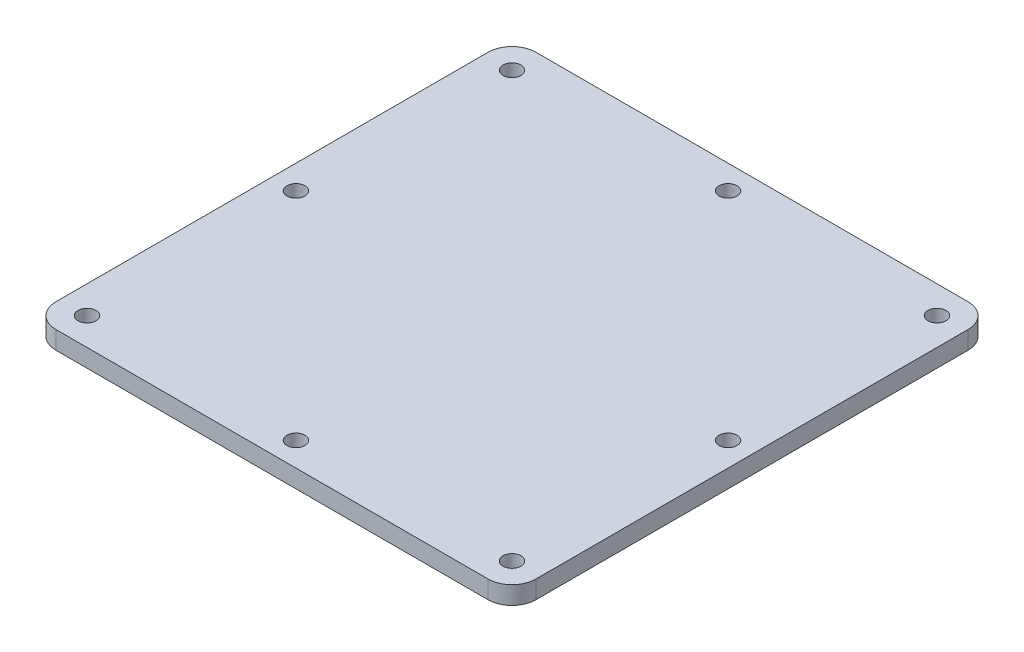
from build123d import *

# Parameters (mm, degrees)
SKETCH_2_W               = 80
SKETCH_2_H               = 80
EXTRUDE_1_DEPTH          = 3
SKETCH_3_R               = 1.5
CUT_EXTRUDE_1_DEPTH      = 3
PATTERN_CIRCULAR_1_COUNT = 4
FILLET_1_R               = 4


with BuildPart() as part:
    # 草图2 → 凸台-拉伸1 (new body)
    with BuildSketch(Plane(origin=(0, 0, 0), x_dir=(1, 0, 0), z_dir=(0, 1, 0))):
        Rectangle(SKETCH_2_W, SKETCH_2_H)
    extrude(amount=EXTRUDE_1_DEPTH)

    # 草图3 → 切除-拉伸1 (cut)
    with BuildSketch(Plane(origin=(0, 0, 0), x_dir=(1, 0, 0), z_dir=(0, 1, 0))):
        with Locations((0, -36)):
            Circle(SKETCH_3_R)
        with Locations((-35.403805922, -35.403805922)):
            Circle(SKETCH_3_R)
    cut_extrude_1 = extrude(amount=CUT_EXTRUDE_1_DEPTH, mode=Mode.SUBTRACT)

    # 阵列(圆周)1: 切除-拉伸1 ×4 about axis
    pattern_circular_1_axis = Axis((0, 3.15, 0), (0, -1, 0))
    for i in range(1, PATTERN_CIRCULAR_1_COUNT):
        add(cut_extrude_1.rotate(pattern_circular_1_axis, i * 360 / PATTERN_CIRCULAR_1_COUNT), mode=Mode.SUBTRACT)

    # 圆角1
    fillet_1_edges = [part.edges().sort_by_distance(p)[0] for p in [
        (40, 1.5, -40),
        (40, 1.5, 40),
        (-40, 1.5, -40),
        (-40, 1.5, 40),
    ]]
    fillet(fillet_1_edges, radius=FILLET_1_R)


solid = part.part
